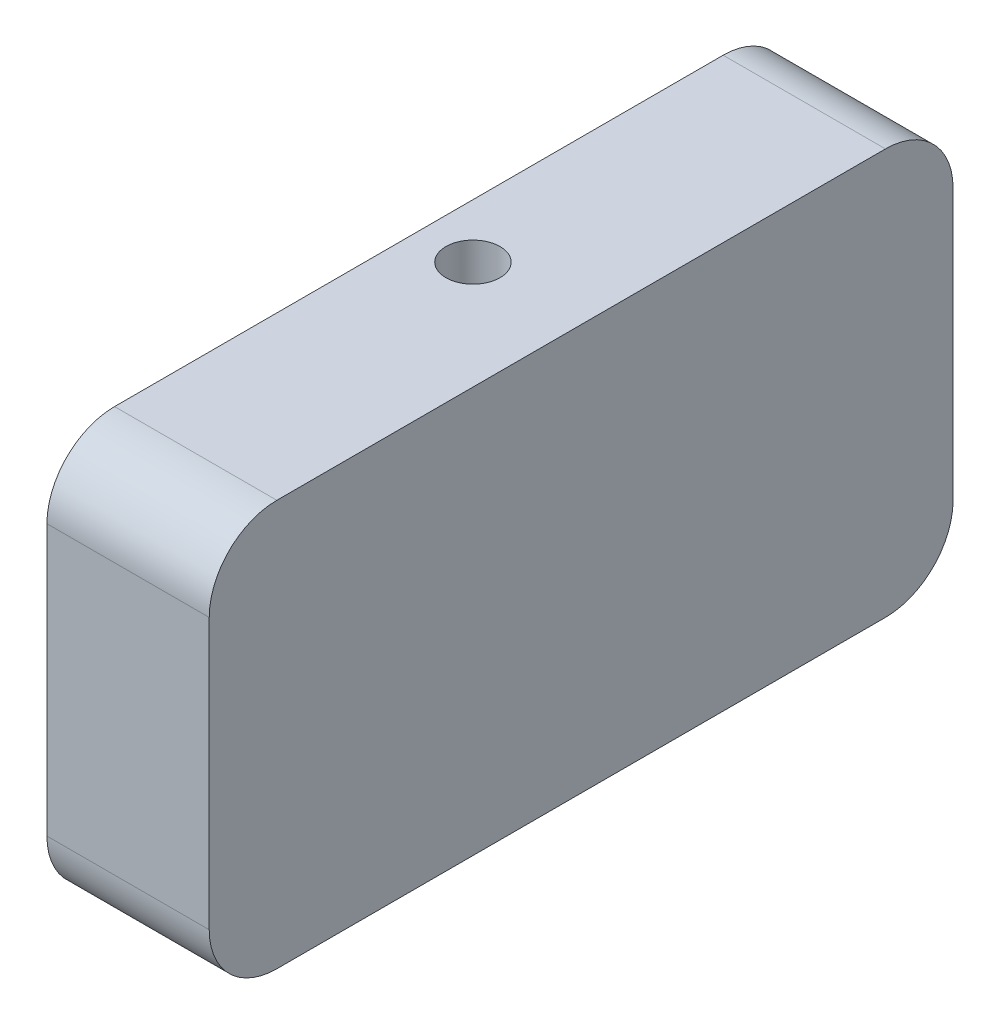
from build123d import *

# Parameters (mm, degrees)
EXTRUDE_1_DEPTH     = 12
SKETCH_2_R          = 8
CUT_EXTRUDE_1_DEPTH = 8
SKETCH_3_R          = 2
CUT_EXTRUDE_2_DEPTH = 40


with BuildPart() as part:
    # 草图1 → 凸台-拉伸1 (new body)
    with BuildSketch(Plane(origin=(0, 0, 0), x_dir=(0, 0, -1), z_dir=(1, 0, 0))):
        with BuildLine():
            Line((-22.5, 15), (22.5, 15))
            ThreePointArc((22.5, 15), (26.035533906, 13.535533906), (27.5, 10))
            Line((27.5, 10), (27.5, -10))
            ThreePointArc((27.5, -10), (26.035533906, -13.535533906), (22.5, -15))
            Line((22.5, -15), (-22.5, -15))
            ThreePointArc((-22.5, -15), (-26.035533906, -13.535533906), (-27.5, -10))
            Line((-27.5, -10), (-27.5, 10))
            ThreePointArc((-27.5, 10), (-26.035533906, 13.535533906), (-22.5, 15))
        make_face()
    extrude(amount=EXTRUDE_1_DEPTH)

    # 草图2 → 切除-拉伸1 (cut)
    with BuildSketch(Plane.ZY):
        Circle(SKETCH_2_R)
    extrude(amount=-CUT_EXTRUDE_1_DEPTH, mode=Mode.SUBTRACT)

    # 草图3 → 切除-拉伸2 (cut)
    with BuildSketch(Plane.XZ.offset(15)):
        with Locations((4, 0)):
            Circle(SKETCH_3_R)
    extrude(amount=-CUT_EXTRUDE_2_DEPTH, mode=Mode.SUBTRACT)


solid = part.part
